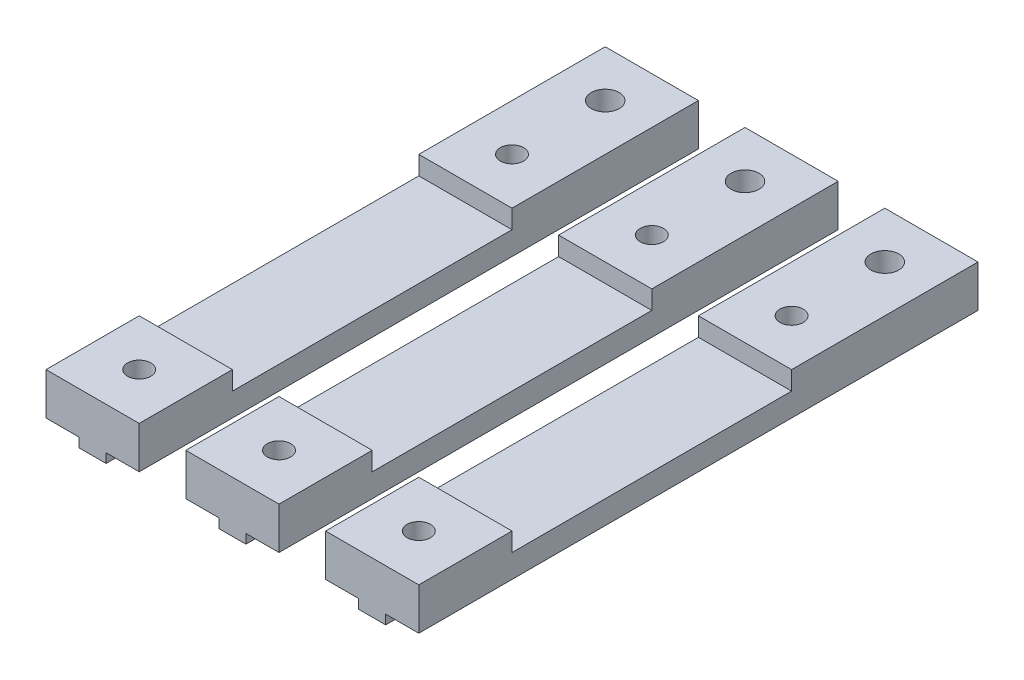
from build123d import *

# Parameters (mm, degrees)
MAIN_DEPTH            = 60
SKETCH2_R             = 1.25
SKETCH2_R_2           = 1.5
I2CBOARDFIXHOLE_DEPTH = 6.5
SKETCH3_W             = 10
SKETCH3_H             = 30
PINS_DEPTH            = 2
LPATTERN1_COUNT       = 3
LPATTERN1_PITCH       = 15


with BuildPart() as part:
    # Sketch1 → Main (new body)
    with BuildSketch(Plane.XY):
        Polygon((-5, 0), (5, 0), (5, -4.5), (1.45, -4.5), (1.45, -5.5), (-1.45, -5.5), (-1.45, -4.5), (-5, -4.5), align=None)
    extrude(amount=MAIN_DEPTH)

    # Sketch2 → I2CBoardFixHole (cut, through all)
    with BuildSketch(Plane(origin=(0, 0, 0), x_dir=(1, 0, 0), z_dir=(0, 1, 0))):
        with Locations((0, -55)):
            Circle(SKETCH2_R)
        with Locations((0, -15)):
            Circle(SKETCH2_R)
        with Locations((0, -5)):
            Circle(SKETCH2_R_2)
    extrude(amount=-I2CBOARDFIXHOLE_DEPTH, mode=Mode.SUBTRACT)

    # Sketch3 → Pins (cut)
    with BuildSketch(Plane(origin=(0, 0, 0), x_dir=(1, 0, 0), z_dir=(0, 1, 0))):
        with Locations((0, -35)):
            Rectangle(SKETCH3_W, SKETCH3_H)
    extrude(amount=-PINS_DEPTH, mode=Mode.SUBTRACT)


with BuildPart() as lpattern1_1:
    # LPattern1: pattern copy
    add(part.part.moved(Location(Vector(-1, 0, 0) * (1 * LPATTERN1_PITCH))))


with BuildPart() as lpattern1_2:
    # LPattern1: pattern copy
    add(part.part.moved(Location(Vector(-1, 0, 0) * (2 * LPATTERN1_PITCH))))


solid = Compound([part.part, lpattern1_1.part, lpattern1_2.part])
